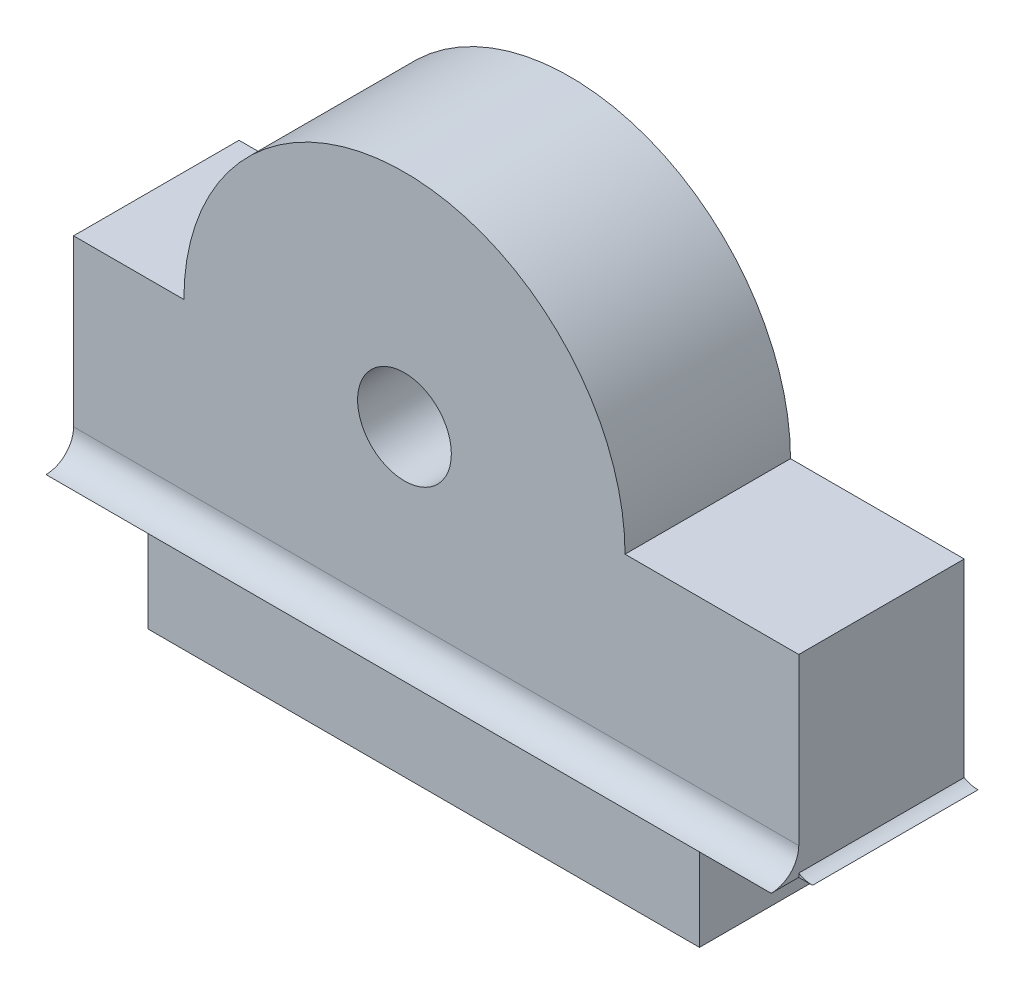
from build123d import *

# Parameters (mm, degrees)
BOSS_EXTRUDE1_DEPTH = 6
BOSS_EXTRUDE2_DEPTH = 26.3
BOSS_EXTRUDE3_DEPTH = 6
SKETCH8_R           = 1.7
BOSS_EXTRUDE4_DEPTH = 3


with BuildPart() as part:
    # Sketch1 → Boss-Extrude1 (new body)
    with BuildSketch(Plane.XY):
        with BuildLine():
            Line((0, 0), (20, 0))
            Line((20, 0), (20, 4))
            Line((20, 4), (23.6, 4))
            Line((23.6, 4), (23.6, 11))
            Line((23.6, 11), (17.3, 11))
            ThreePointArc((17.3, 11), (9.3, 19), (1.3, 11))
            Line((1.3, 11), (-2.7, 11))
            Line((-2.7, 11), (-2.7, 4))
            Line((-2.7, 4), (0, 4))
            Line((0, 4), (0, 0))
        make_face()
        Polygon((11.118653348, 14.15), (7.481346652, 14.15), (5.662693304, 11), (7.481346652, 7.85), (11.118653348, 7.85), (12.937306696, 11), align=None, mode=Mode.SUBTRACT)
    extrude(amount=BOSS_EXTRUDE1_DEPTH)

    # Sketch2 → Boss-Extrude2 (add)
    with BuildSketch(Plane.ZY.offset(2.7)):
        with BuildLine():
            Line((6, 4), (6, 5))
            ThreePointArc((6, 5), (6.292893219, 4.292893219), (7, 4))
            Line((7, 4), (6, 4))
        make_face()
    extrude(amount=-BOSS_EXTRUDE2_DEPTH)

    # Sketch4 → Boss-Extrude3 (add)
    with BuildSketch(Plane.XY.offset(6)):
        with BuildLine():
            Line((23.1, 4), (23.1, 5))
            ThreePointArc((23.1, 5), (23.392893219, 4.292893219), (24.1, 4))
            Line((24.1, 4), (23.1, 4))
        make_face()
        with BuildLine():
            Line((-1.5, 4), (-2.5, 4))
            ThreePointArc((-2.5, 4), (-1.792893219, 4.292893219), (-1.5, 5))
            Line((-1.5, 5), (-1.5, 4))
        make_face()
    extrude(amount=-BOSS_EXTRUDE3_DEPTH)

    # Sketch8 → Boss-Extrude4 (add)
    with BuildSketch(Plane.XY.offset(6)):
        Polygon((7.452479139, 14.2), (5.604958277, 11), (7.452479139, 7.8), (11.147520861, 7.8), (12.995041723, 11), (11.147520861, 14.2), align=None)
        with Locations((9.3, 11)):
            Circle(SKETCH8_R, mode=Mode.SUBTRACT)
    extrude(amount=-BOSS_EXTRUDE4_DEPTH)


solid = part.part
